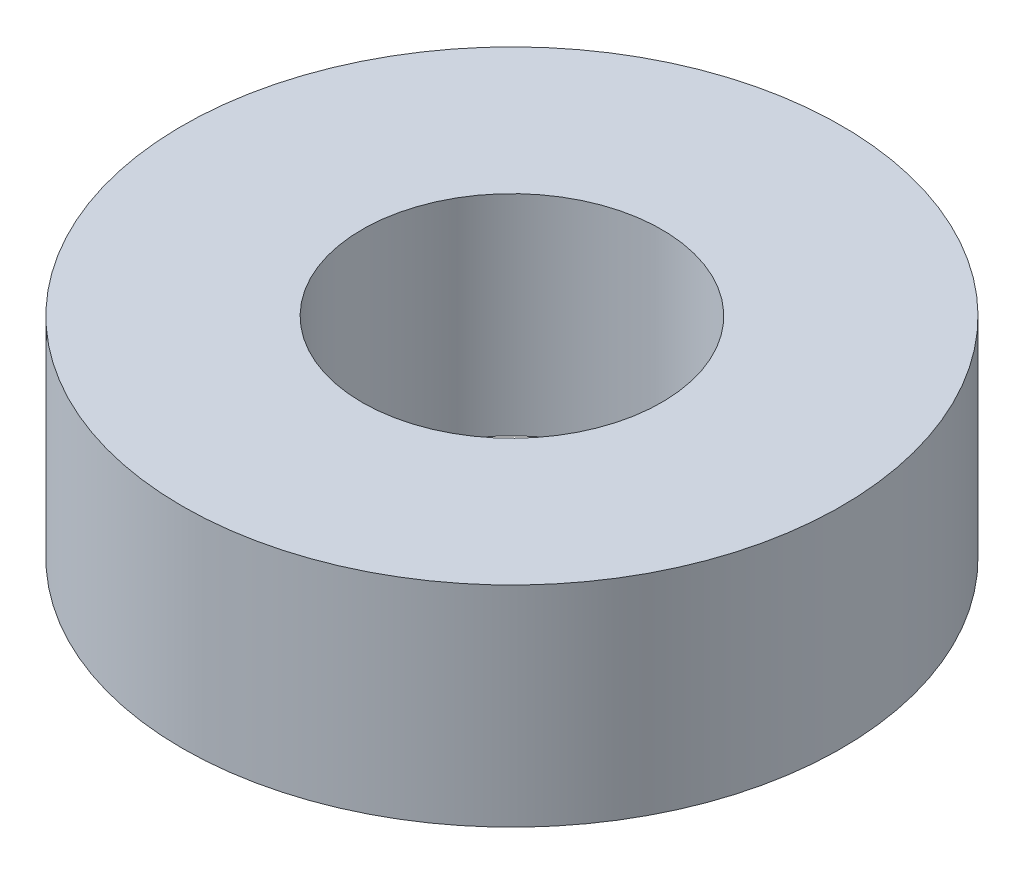
from build123d import *

# Parameters (mm, degrees)
SKETCH1_R           = 17.4625
SKETCH1_R_2         = 7.9375
BOSS_EXTRUDE1_DEPTH = 11.1125


with BuildPart() as part:
    # Sketch1 → Boss-Extrude1 (new body)
    with BuildSketch(Plane(origin=(0, 0, 0), x_dir=(1, 0, 0), z_dir=(0, 1, 0))):
        Circle(SKETCH1_R)
        Circle(SKETCH1_R_2, mode=Mode.SUBTRACT)
    extrude(amount=BOSS_EXTRUDE1_DEPTH)


solid = part.part
